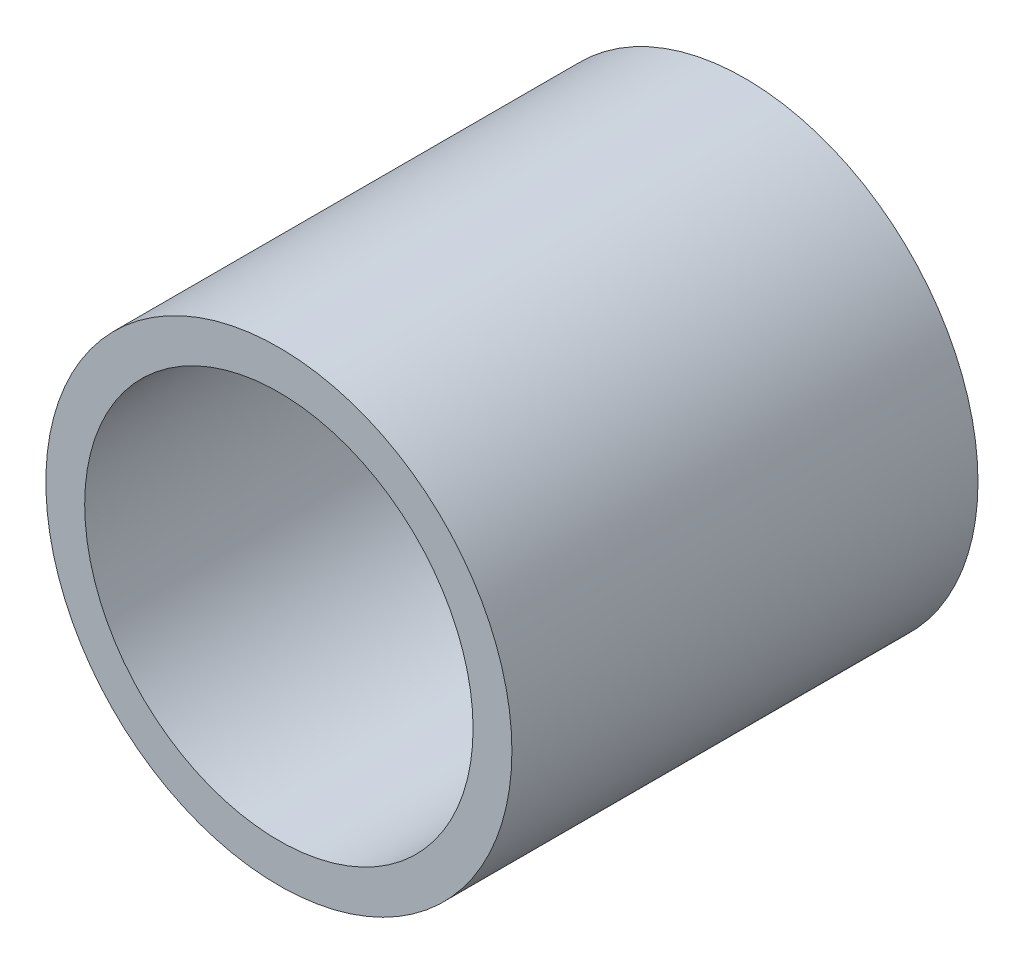
from build123d import *

# Parameters (mm, degrees)
SKETCH_1_R          = 12
EXTRUDE_1_DEPTH     = 4
SKETCH_2_R          = 12
SKETCH_2_R_2        = 10
EXTRUDE_2_DEPTH     = 20
SKETCH_4_R          = 1.5
CUT_EXTRUDE_1_DEPTH = 25
SKETCH_6_R          = 2.5
CUT_EXTRUDE_2_DEPTH = 3.5
SKETCH_7_R          = 1
CUT_EXTRUDE_3_DEPTH = 25


with BuildPart() as part:
    # 스케치1 → 보스-돌출1 (new body)
    with BuildSketch(Plane.XY):
        Circle(SKETCH_1_R)
    extrude(amount=EXTRUDE_1_DEPTH)

    # 스케치2 → 보스-돌출2 (add)
    with BuildSketch(Plane.XY.offset(4)):
        Circle(SKETCH_2_R)
        Circle(SKETCH_2_R_2, mode=Mode.SUBTRACT)
    extrude(amount=EXTRUDE_2_DEPTH)

    # 스케치4 → 컷-돌출1 (cut, through all)
    with BuildSketch(Plane(origin=(0, 0, 0), x_dir=(-1, 0, 0), z_dir=(0, 0, -1))):
        Circle(SKETCH_4_R)
    extrude(amount=-CUT_EXTRUDE_1_DEPTH, mode=Mode.SUBTRACT)

    # 스케치6 → 컷-돌출2 (cut)
    with BuildSketch(Plane(origin=(0, 0, 0), x_dir=(-1, 0, 0), z_dir=(0, 0, -1))):
        Circle(SKETCH_6_R)
    extrude(amount=-CUT_EXTRUDE_2_DEPTH, mode=Mode.SUBTRACT)

    # 스케치7 → 컷-돌출3 (cut, through all)
    with BuildSketch(Plane(origin=(0, 0, 0), x_dir=(-1, 0, 0), z_dir=(0, 0, -1))):
        with Locations((-5, 0)):
            Circle(SKETCH_7_R)
        with Locations((5, 0)):
            Circle(SKETCH_7_R)
    extrude(amount=-CUT_EXTRUDE_3_DEPTH, mode=Mode.SUBTRACT)


solid = part.part
